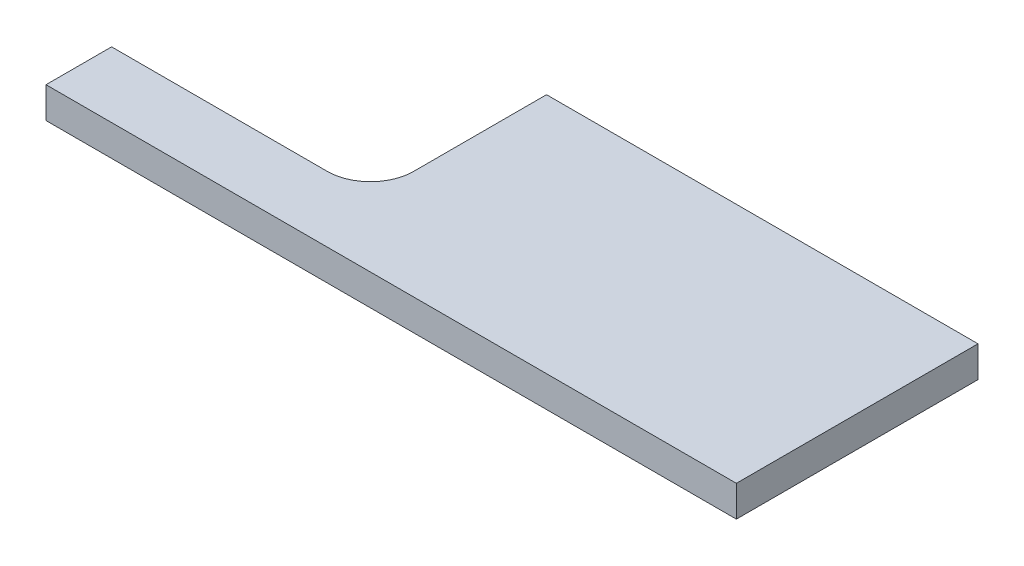
from build123d import *

# Parameters (mm, degrees)
BOSS_EXTRUDE1_DEPTH = 18


with BuildPart() as part:
    # Sketch1 → Boss-Extrude1 (new body)
    with BuildSketch(Plane(origin=(0, 0, 0), x_dir=(1, 0, 0), z_dir=(0, 1, 0))):
        with BuildLine():
            Line((66.981499187, 102), (316.981499187, 102))
            Line((316.981499187, 102), (316.981499187, -38))
            Line((316.981499187, -38), (-83.018500813, -38))
            Line((-83.018500813, -38), (-83.018500813, 0))
            Line((-83.018500813, 0), (41.981499187, 0))
            ThreePointArc((41.981499187, 0), (59.659168717, 7.32233047), (66.981499187, 25))
            Line((66.981499187, 25), (66.981499187, 102))
        make_face()
    extrude(amount=BOSS_EXTRUDE1_DEPTH)


solid = part.part
